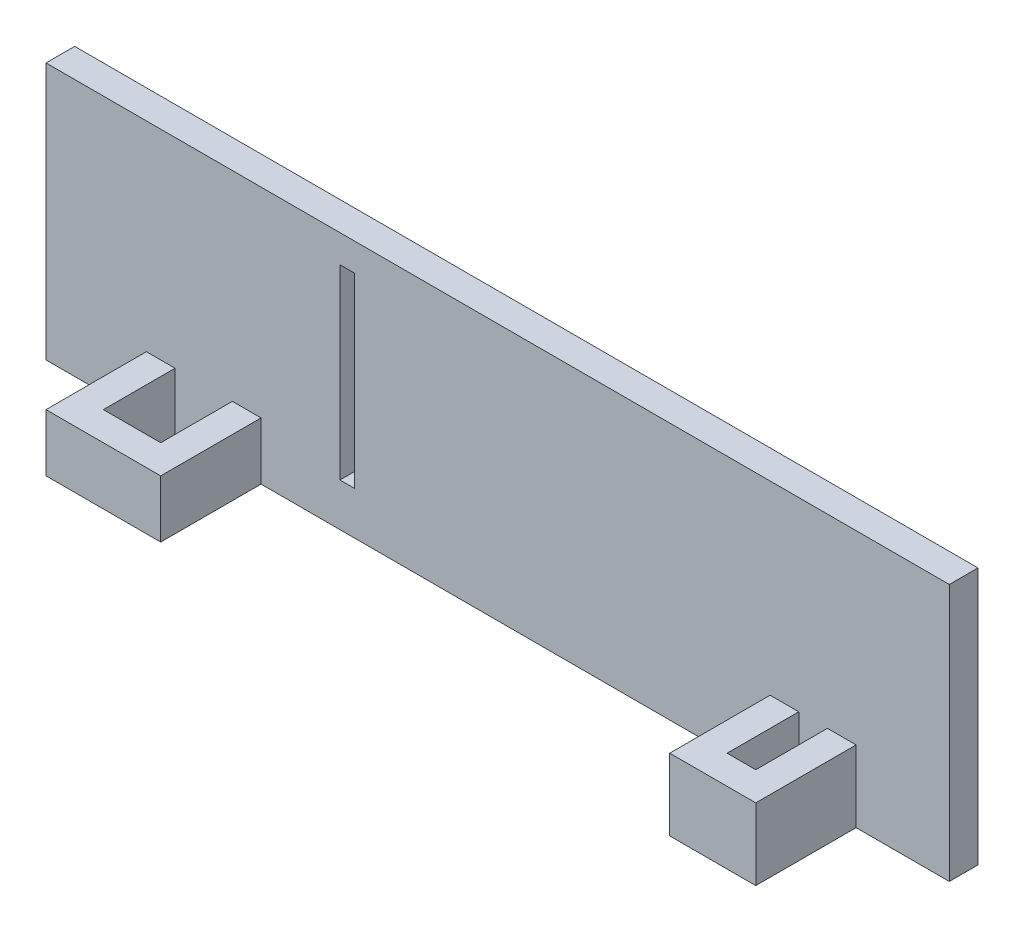
from build123d import *

# Parameters (mm, degrees)
P_IDAT_VYSUNUT_M1_DEPTH        = 2
SKICA3_R                       = 2.45
P_IDAT_VYSUNUT_M3_DEPTH        = 5
P_IDAT_VYSUNUT_M4_DEPTH        = 37.5
SKICA8_W                       = 10
SKICA8_H                       = 10
ODEBRAT_VYSUNUT_M2_DEPTH       = 4
SKICA10_W                      = 27.5
SKICA10_H                      = 79
ODEBRAT_VYSUNUT_M3_DEPTH       = 3
P_IDAT_VYSUNUT_M5_DEPTH        = 1
SKICA13_W                      = 3
SKICA13_H                      = 36.5
ODEBRAT_VYSUNUT_M6_DEPTH       = 103.45
SKICA14_W                      = 3
SKICA14_H                      = 36.5
ODEBRAT_VYSUNUT_M7_DEPTH       = 103.45
SKICA15_W                      = 36.5
SKICA15_H                      = 3
ODEBRAT_VYSUNUT_M8_DEPTH       = 61
SKICA19_W                      = 37
SKICA19_H                      = 13
ODEBRAT_VYSUNUT_M9_DEPTH       = 4
SKICA20_W                      = 63
SKICA20_H                      = 102.45
SKICA20_W_2                    = 57
SKICA20_H_2                    = 79
ODEBRAT_VYSUNUT_M10_DEPTH      = 1
SKICA22_W                      = 8
SKICA22_H                      = 4
SKICA22_W_2                    = 6
SKICA22_H_2                    = 5
P_IDAT_VYSUNUT_M6_DEPTH        = 7
SKICA23_W                      = 4
SKICA23_H                      = 5
SKICA23_W_2                    = 2
ODEBRAT_VYSUNUT_M12_DEPTH      = 5
SKICA25_W                      = 1
SKICA25_H                      = 13
ODEBRAT_VYSUNUT_M13_DEPTH      = 10
SKICA28_W                      = 63
SKICA28_H                      = 84.509642994
ODEBRAT_VYSUNUT_M14_DEPTH      = 8
ODEBRAT_VYSUNUT_M14_DEPTH_BACK = 3


with BuildPart() as part:
    # Skica1 → Přidat vysunutím1 (new body)
    with BuildSketch(Plane.XY):
        Polygon((13, -102.45), (13, -115.45), (50, -115.45), (50, -102.45), (63, -102.45), (63, 0), (0, 0), (0, -102.45), align=None)
    extrude(amount=P_IDAT_VYSUNUT_M1_DEPTH)

    # Skica3 → Přidat vysunutím3 (add)
    with BuildSketch(Plane.XY.offset(2)):
        with Locations((7.55, -6.45)):
            Circle(SKICA3_R)
        with Locations((7.55, -78.45)):
            Circle(SKICA3_R)
        with Locations((55.55, -78.45)):
            Circle(SKICA3_R)
        with Locations((55.55, -6.45)):
            Circle(SKICA3_R)
    extrude(amount=P_IDAT_VYSUNUT_M3_DEPTH)

    # Skica4 → Přidat vysunutím4 (add)
    with BuildSketch(Plane.XY.offset(2)):
        Polygon((63, 0), (63, -102.45), (60, -102.45), (60, -3), (3, -3), (3, -102.45), (0, -102.45), (0, 0), align=None)
    extrude(amount=P_IDAT_VYSUNUT_M4_DEPTH)

    # Skica8 → Odebrat vysunutím2 (cut, through all)
    with BuildSketch(Plane.ZY.offset(-60)):
        with Locations((7, -49)):
            Rectangle(SKICA8_W, SKICA8_H)
    extrude(amount=-ODEBRAT_VYSUNUT_M2_DEPTH, mode=Mode.SUBTRACT)

    # Skica10 → Odebrat vysunutím3 (cut)
    with BuildSketch(Plane.ZY):
        with Locations((25.75, -42.5)):
            Rectangle(SKICA10_W, SKICA10_H)
    extrude(amount=-ODEBRAT_VYSUNUT_M3_DEPTH, mode=Mode.SUBTRACT)

    # Skica11 → Přidat vysunutím5 (add)
    with BuildSketch(Plane.XY.offset(2)):
        Polygon((3, -82), (60, -82), (60, -102.45), (50, -102.45), (50, -115.45), (13, -115.45), (13, -102.45), (3, -102.45), align=None)
    extrude(amount=P_IDAT_VYSUNUT_M5_DEPTH)

    # Skica13 → Odebrat vysunutím6 (cut, through all)
    with BuildSketch(Plane.XZ.offset(102.45)):
        with Locations((1.5, 21.25)):
            Rectangle(SKICA13_W, SKICA13_H)
    extrude(amount=-ODEBRAT_VYSUNUT_M6_DEPTH, mode=Mode.SUBTRACT)

    # Skica14 → Odebrat vysunutím7 (cut, through all)
    with BuildSketch(Plane.XZ.offset(102.45)):
        with Locations((61.5, 21.25)):
            Rectangle(SKICA14_W, SKICA14_H)
    extrude(amount=-ODEBRAT_VYSUNUT_M7_DEPTH, mode=Mode.SUBTRACT)

    # Skica15 → Odebrat vysunutím8 (cut, through all)
    with BuildSketch(Plane.ZY.offset(-3)):
        with Locations((21.25, -1.5)):
            Rectangle(SKICA15_W, SKICA15_H)
    extrude(amount=-ODEBRAT_VYSUNUT_M8_DEPTH, mode=Mode.SUBTRACT)

    # Skica19 → Odebrat vysunutím9 (cut, through all)
    with BuildSketch(Plane.XY.offset(3)):
        with Locations((31.5, -108.95)):
            Rectangle(SKICA19_W, SKICA19_H)
    extrude(amount=-ODEBRAT_VYSUNUT_M9_DEPTH, mode=Mode.SUBTRACT)

    # Skica20 → Odebrat vysunutím10 (cut)
    with BuildSketch(Plane.XY.offset(3)):
        with Locations((31.5, -51.225)):
            Rectangle(SKICA20_W, SKICA20_H)
        with Locations((31.5, -42.5)):
            Rectangle(SKICA20_W_2, SKICA20_H_2, mode=Mode.SUBTRACT)
    extrude(amount=-ODEBRAT_VYSUNUT_M10_DEPTH, mode=Mode.SUBTRACT)

    # Skica22 → Přidat vysunutím6 (add)
    with BuildSketch(Plane.XY.offset(2)):
        with Locations((11, -100.45)):
            Rectangle(SKICA22_W, SKICA22_H)
        with Locations((53.5, -99.95)):
            Rectangle(SKICA22_W_2, SKICA22_H_2)
    extrude(amount=P_IDAT_VYSUNUT_M6_DEPTH)

    # Skica23 → Odebrat vysunutím12 (cut)
    with BuildSketch(Plane.XZ.offset(102.45)):
        with Locations((11, 4.5)):
            Rectangle(SKICA23_W, SKICA23_H)
        with Locations((53.5, 4.5)):
            Rectangle(SKICA23_W_2, SKICA23_H)
    extrude(amount=-ODEBRAT_VYSUNUT_M12_DEPTH, mode=Mode.SUBTRACT)

    # Skica25 → Odebrat vysunutím13 (cut)
    with BuildSketch(Plane.XY.offset(2)):
        with Locations((21, -92.95)):
            Rectangle(SKICA25_W, SKICA25_H)
    extrude(amount=-ODEBRAT_VYSUNUT_M13_DEPTH, mode=Mode.SUBTRACT)

    # Skica28 → Odebrat vysunutím14 (cut, two sides)
    with BuildSketch(Plane.XY.offset(2)) as odebrat_vysunut_m14_sk:
        with Locations((31.5, -42.254821497)):
            Rectangle(SKICA28_W, SKICA28_H)
    extrude(amount=ODEBRAT_VYSUNUT_M14_DEPTH, mode=Mode.SUBTRACT)
    extrude(odebrat_vysunut_m14_sk.sketch, amount=-ODEBRAT_VYSUNUT_M14_DEPTH_BACK, mode=Mode.SUBTRACT)


solid = part.part
